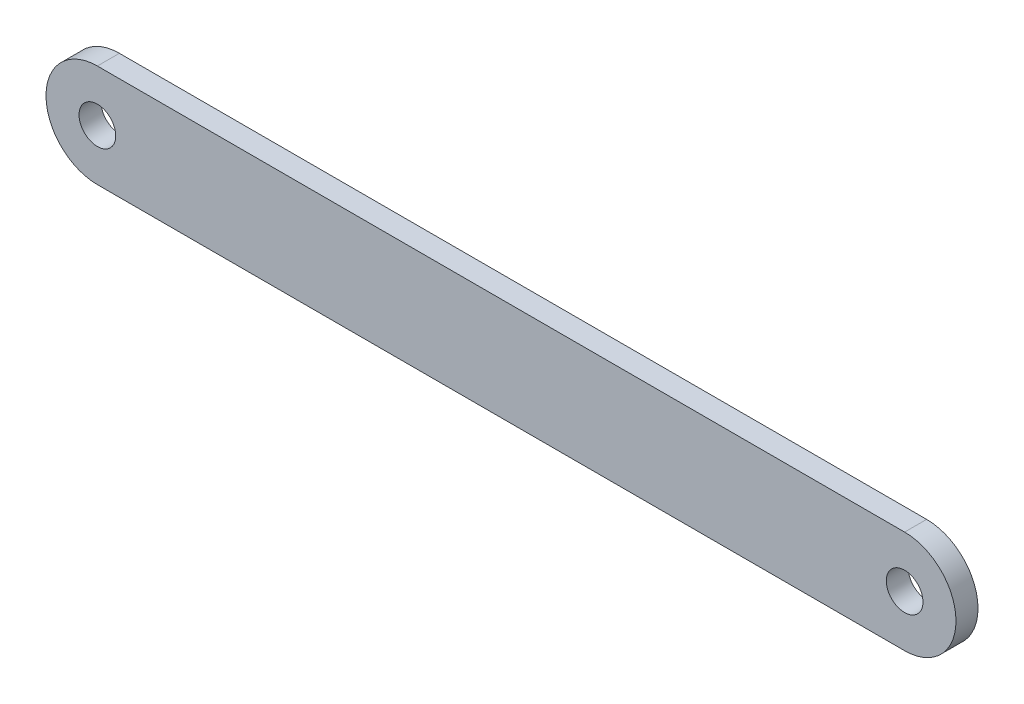
from build123d import *

# Parameters (mm, degrees)
SKETCH1_R           = 2.5
BOSS_EXTRUDE1_DEPTH = 3


with BuildPart() as part:
    # Sketch1 → Boss-Extrude1 (new body)
    with BuildSketch(Plane.XY):
        with BuildLine():
            Line((-70.959009299, 269.154117688), (39.040990701, 269.154117688))
            ThreePointArc((39.040990701, 269.154117688), (46.040990701, 262.154117688), (39.040990701, 255.154117688))
            Line((39.040990701, 255.154117688), (-70.959009299, 255.154117688))
            ThreePointArc((-70.959009299, 255.154117688), (-77.959009299, 262.154117688), (-70.959009299, 269.154117688))
        make_face()
        with Locations((-70.959009299, 262.154117688)):
            Circle(SKETCH1_R, mode=Mode.SUBTRACT)
        with Locations((39.040990701, 262.154117688)):
            Circle(SKETCH1_R, mode=Mode.SUBTRACT)
    extrude(amount=BOSS_EXTRUDE1_DEPTH)


solid = part.part
